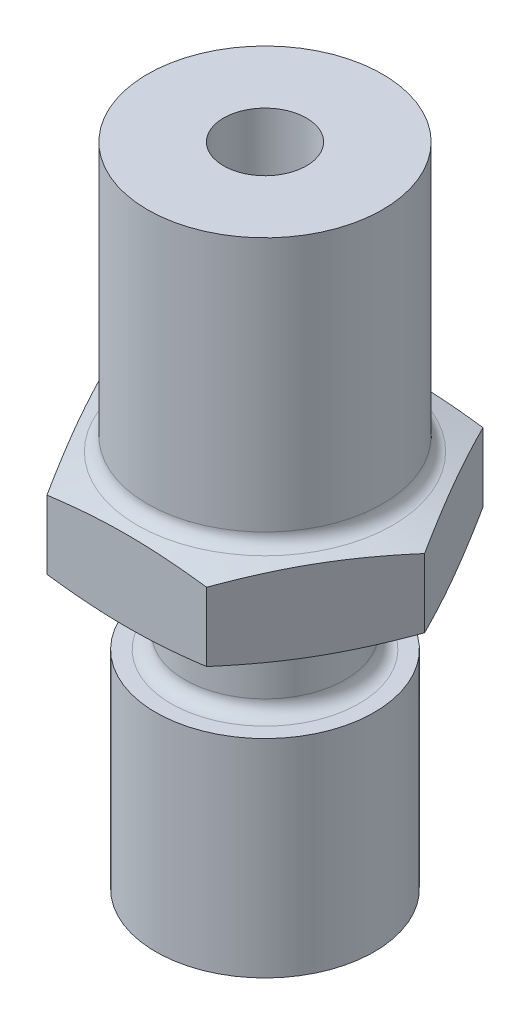
from build123d import *

# Parameters (mm, degrees)
SKETCH1_R           = 4.25
BOSS_EXTRUDE1_DEPTH = 9.6
BOSS_EXTRUDE2_DEPTH = 3.3
SKETCH3_OUTSIDE_W   = 42.178
SKETCH3_OUTSIDE_H   = 40.63
SKETCH3_OUTSIDE_R   = 4.25
CUT_EXTRUDE4_DEPTH  = 3.3
CUT_EXTRUDE4_TAPER  = 75
SKETCH5_OUTSIDE_W   = 42.178
SKETCH5_OUTSIDE_H   = 40.63
SKETCH5_OUTSIDE_R   = 4.25
CUT_EXTRUDE5_DEPTH  = 3.3
CUT_EXTRUDE5_TAPER  = 75
SKETCH6_R           = 2.9
BOSS_EXTRUDE3_DEPTH = 3
SKETCH7_R           = 3.95
BOSS_EXTRUDE4_DEPTH = 7.5
SKETCH8_R           = 1.5
CUT_EXTRUDE6_DEPTH  = 24.4
SKETCH9_R           = 2.25
CUT_EXTRUDE7_DEPTH  = 10
FILLET1_R           = 0.5
SKETCH10_R          = 1.5
CUT_EXTRUDE8_DEPTH  = 6.0000001
CHAMFER1_SIZE       = 1


with BuildPart() as part:
    # Sketch1 → Boss-Extrude1 (new body)
    with BuildSketch(Plane(origin=(0, 0, 0), x_dir=(1, 0, 0), z_dir=(0, 1, 0))):
        Circle(SKETCH1_R)
    extrude(amount=BOSS_EXTRUDE1_DEPTH)

    # Sketch2 → Boss-Extrude2 (add)
    with BuildSketch(Plane.XZ):
        Polygon((-2.886751346, 5), (-5.773502692, 0), (-2.886751346, -5), (2.886751346, -5), (5.773502692, 0), (2.886751346, 5), align=None)
    extrude(amount=BOSS_EXTRUDE2_DEPTH)

    # Sketch3 outside → Cut-Extrude4 (cut)
    with BuildSketch(Plane.XZ.offset(3.3)):
        Rectangle(SKETCH3_OUTSIDE_W, SKETCH3_OUTSIDE_H)
        Circle(SKETCH3_OUTSIDE_R, mode=Mode.SUBTRACT)
    extrude(amount=-CUT_EXTRUDE4_DEPTH, taper=CUT_EXTRUDE4_TAPER, mode=Mode.SUBTRACT)

    # Sketch5 outside → Cut-Extrude5 (cut)
    with BuildSketch(Plane(origin=(0, 0, 0), x_dir=(1, 0, 0), z_dir=(0, 1, 0))):
        Rectangle(SKETCH5_OUTSIDE_W, SKETCH5_OUTSIDE_H)
        Circle(SKETCH5_OUTSIDE_R, mode=Mode.SUBTRACT)
    extrude(amount=-CUT_EXTRUDE5_DEPTH, taper=CUT_EXTRUDE5_TAPER, mode=Mode.SUBTRACT)

    # Sketch6 → Boss-Extrude3 (add)
    with BuildSketch(Plane.XZ.offset(3.3)):
        Circle(SKETCH6_R)
    extrude(amount=BOSS_EXTRUDE3_DEPTH)

    # Sketch7 → Boss-Extrude4 (add)
    with BuildSketch(Plane.XZ.offset(6.3)):
        Circle(SKETCH7_R)
    extrude(amount=BOSS_EXTRUDE4_DEPTH)

    # Sketch8 → Cut-Extrude6 (cut, through all)
    with BuildSketch(Plane.XZ.offset(13.8)):
        Circle(SKETCH8_R)
    extrude(amount=-CUT_EXTRUDE6_DEPTH, mode=Mode.SUBTRACT)

    # Sketch9 → Cut-Extrude7 (cut)
    with BuildSketch(Plane.XZ.offset(13.8)):
        Circle(SKETCH9_R)
    extrude(amount=-CUT_EXTRUDE7_DEPTH, mode=Mode.SUBTRACT)

    # Fillet1
    fillet1_edges = [part.edges().sort_by_distance(p)[0] for p in [
        (-4.25, 0, 0),
        (-2.9, -3.3, 0),
        (-2.9, -6.3, 0),
    ]]
    fillet(fillet1_edges, radius=FILLET1_R)

    # Sketch10 → Cut-Extrude8 (cut, through all)
    with BuildSketch(Plane.XY):
        with Locations((0, 5.6)):
            Circle(SKETCH10_R)
    extrude(amount=-CUT_EXTRUDE8_DEPTH, mode=Mode.SUBTRACT)

    # Chamfer1
    chamfer1_edges = [part.edges().sort_by_distance(p)[0] for p in [
        (-2.25, -13.8, 0),
    ]]
    chamfer(chamfer1_edges, length=CHAMFER1_SIZE)


solid = part.part
